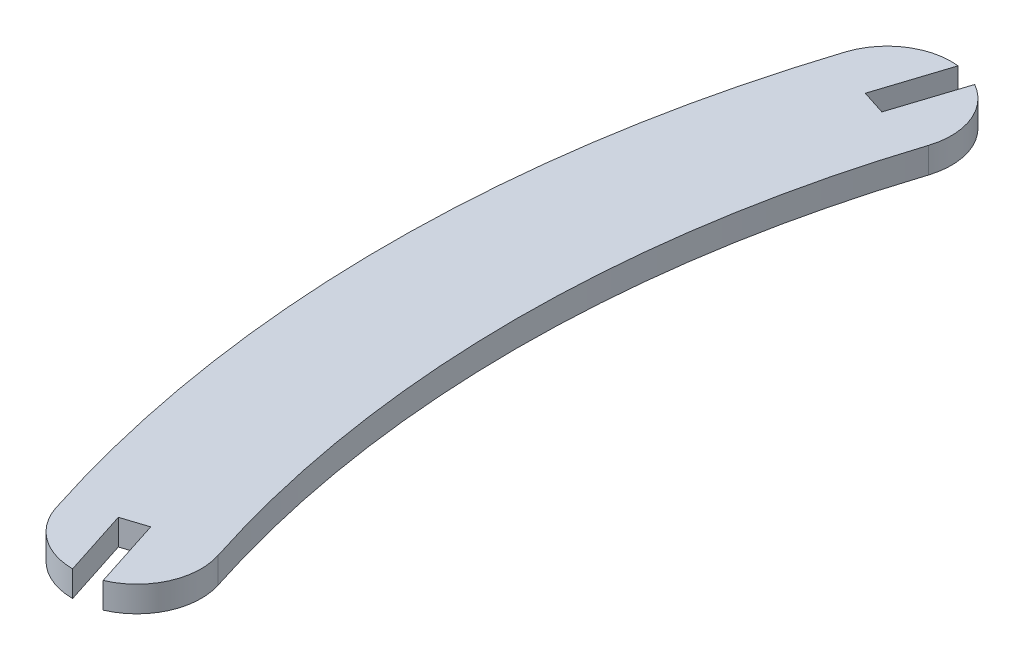
from build123d import *

# Parameters (mm, degrees)
SALIENTE_EXTRUIR1_DEPTH = 3


with BuildPart() as part:
    # Croquis2 → Saliente-Extruir1 (new body)
    with BuildSketch(Plane(origin=(0, 0, 0), x_dir=(1, 0, 0), z_dir=(0, 1, 0))):
        with BuildLine():
            Line((-134.790190036, 51.201608082), (-137.430390036, 43.016906257))
            Line((-137.430390036, 43.016906257), (-134.575261492, 42.095906257))
            Line((-134.575261492, 42.095906257), (-131.935061492, 50.280608082))
            ThreePointArc((-131.935061492, 50.280608082), (-128.633444304, 46.478345774), (-128.480784458, 41.445))
            ThreePointArc((-128.480784458, 41.445), (-135, 0), (-128.480784458, -41.445))
            ThreePointArc((-128.480784458, -41.445), (-128.791366857, -46.852143005), (-132.662267215, -50.640254317))
            Line((-132.662267215, -50.640254317), (-135.302467215, -42.455552492))
            Line((-135.302467215, -42.455552492), (-138.157595759, -43.376552492))
            Line((-138.157595759, -43.376552492), (-135.618605817, -51.2475))
            ThreePointArc((-135.618605817, -51.2475), (-140.033424613, -49.810451014), (-142.756427176, -46.05))
            ThreePointArc((-142.756427176, -46.05), (-150, 0), (-142.756427176, 46.05))
            ThreePointArc((-142.756427176, 46.05), (-139.691309605, 50.045363436), (-134.790190036, 51.201608082))
        make_face()
    extrude(amount=SALIENTE_EXTRUIR1_DEPTH)


solid = part.part
